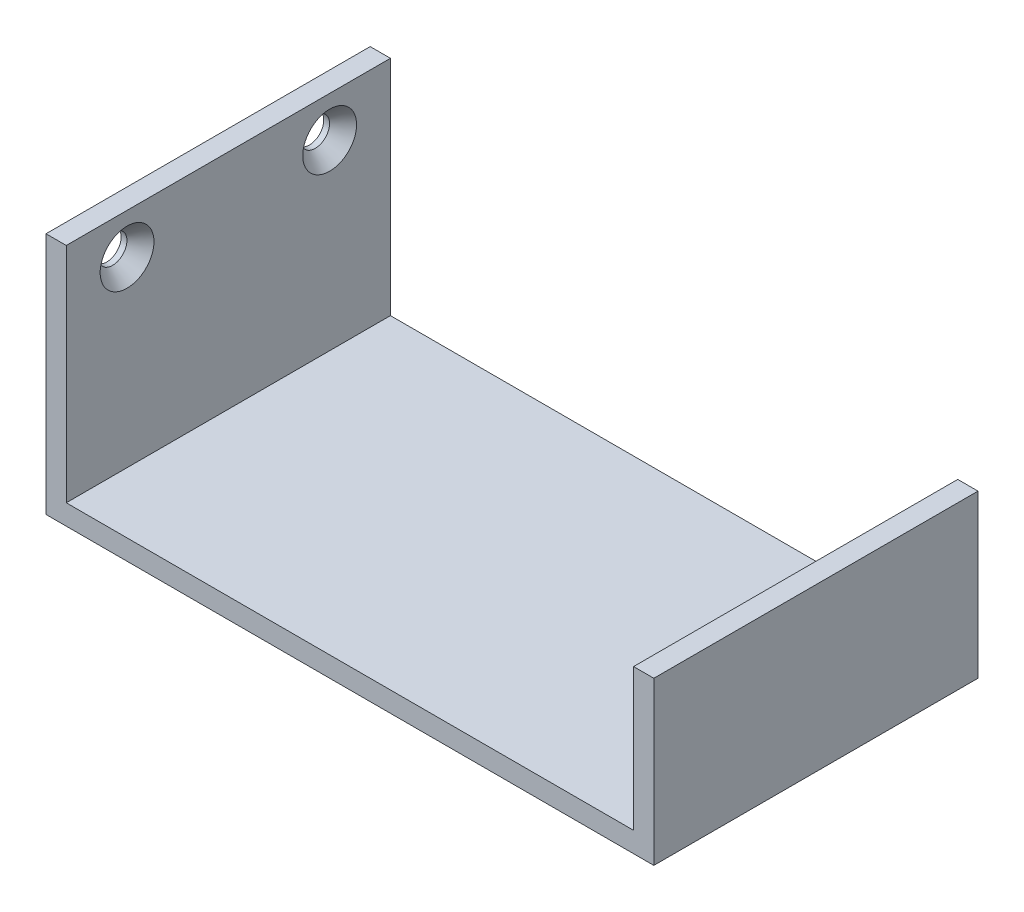
from build123d import *

# Parameters (mm, degrees)
BOSS_EXTRUDE1_DEPTH                           = 50.8
CSK_FOR_8_FLAT_HEAD_MACHINE_SCREW1_AT_2_COUNT = 2
CSK_FOR_8_FLAT_HEAD_MACHINE_SCREW1_AT_2_PITCH = 31.75


with BuildPart() as part:
    # Sketch1 → Boss-Extrude1 (new body)
    with BuildSketch(Plane.XY):
        Polygon((0, 0), (0, 38.1), (3.175, 38.1), (3.175, 3.175), (92.075, 3.175), (92.075, 25.4), (95.25, 25.4), (95.25, 0), align=None)
    extrude(amount=BOSS_EXTRUDE1_DEPTH)

    # Sketch3 → CSK for #8 Flat Head Machine Screw1 (revolve, cut)
    with BuildSketch(Plane(origin=(3.175, 31.75, 41.275), x_dir=(0, 0, -1), z_dir=(0, 1, 0))):
        Polygon((0, 0), (0, 3.175), (2.2479, 3.175), (2.2479, 2.26450021), (4.2164, 0), align=None)
    csk_for_8_flat_head_machine_screw1 = revolve(axis=Axis((9.525, 31.75, 41.275), (-1, 0, 0)), mode=Mode.SUBTRACT)

    # CSK for #8 Flat Head Machine Screw1 at 2: CSK for #8 Flat Head Machine Screw1 ×2
    with Locations(*[(0, 0, -i * CSK_FOR_8_FLAT_HEAD_MACHINE_SCREW1_AT_2_PITCH) for i in range(1, CSK_FOR_8_FLAT_HEAD_MACHINE_SCREW1_AT_2_COUNT)]):
        add(csk_for_8_flat_head_machine_screw1, mode=Mode.SUBTRACT)


solid = part.part
